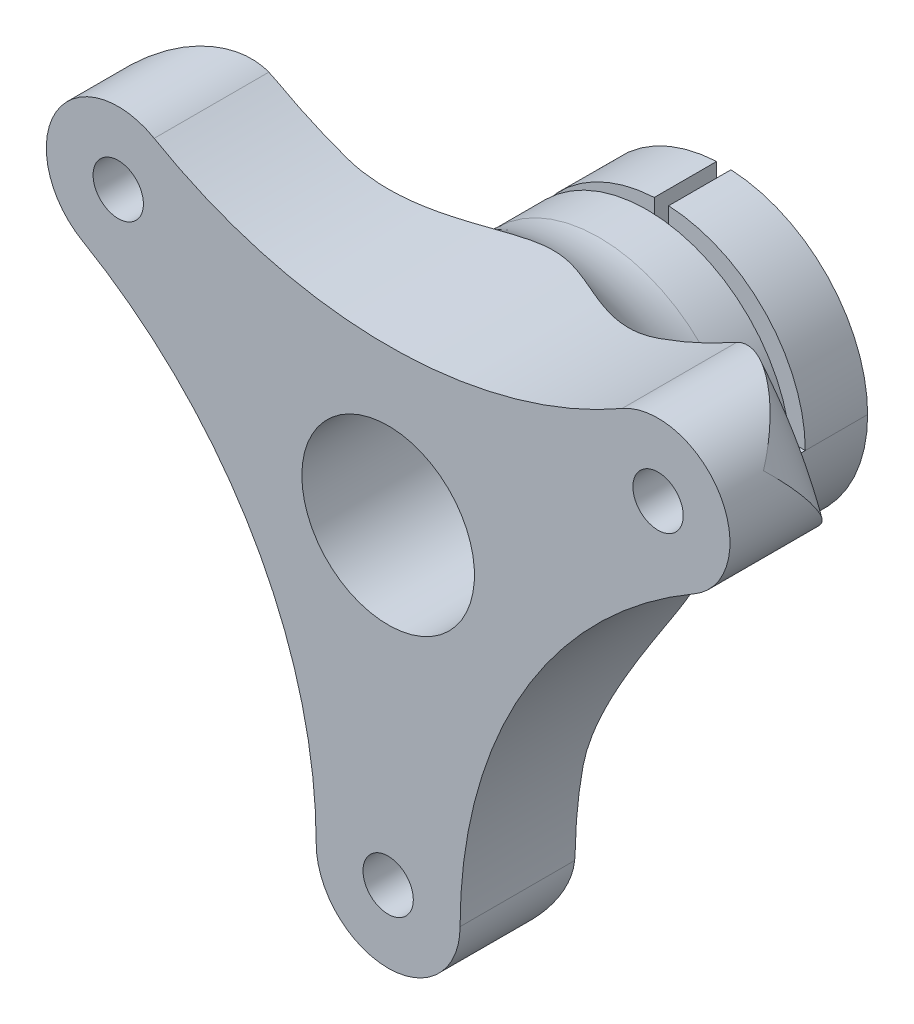
from build123d import *

# Parameters (mm, degrees)
SKETCH2_R          = 11.1125
CUT_EXTRUDE1_DEPTH = 15.875
SKETCH3_W          = 35
SKETCH3_H          = 1.5
CUT_EXTRUDE2_DEPTH = 15.875
SKETCH4_W          = 1.5
SKETCH4_H          = 35
CUT_EXTRUDE3_DEPTH = 8
SKETCH8_OUTSIDE_W  = 105.686
SKETCH8_OUTSIDE_H  = 105.686
CUT_EXTRUDE4_DEPTH = 36
SKETCH9_R          = 9
CUT_EXTRUDE5_DEPTH = 20.1250001
SKETCH5_R          = 2.625
CUT_EXTRUDE7_DEPTH = 36
SKETCH11_R         = 4
CUT_EXTRUDE8_DEPTH = 5


with BuildPart() as part:
    # Sketch1 → Revolve1 (revolve)
    with BuildSketch(Plane(origin=(0, 0, 0), x_dir=(1, 0, 0), z_dir=(0, 1, 0))):
        with BuildLine():
            Line((0, 0), (40, 0))
            Line((40, 0), (40, 4.5))
            ThreePointArc((40, 4.5), (37.803300859, 9.803300859), (32.5, 12))
            Line((32.5, 12), (25, 12))
            ThreePointArc((25, 12), (17.928932188, 14.928932188), (15, 22))
            Line((15, 22), (15, 35))
            Line((15, 35), (0, 35))
            Line((0, 35), (0, 0))
        make_face()
    revolve(axis=Axis((0, 0, 0), (0, 0, -1)))

    # Sketch2 → Cut-Extrude1 (cut)
    with BuildSketch(Plane(origin=(0, 0, -35), x_dir=(-1, 0, 0), z_dir=(0, 0, -1))):
        Circle(SKETCH2_R)
    extrude(amount=-CUT_EXTRUDE1_DEPTH, mode=Mode.SUBTRACT)

    # Sketch3 → Cut-Extrude2 (cut)
    with BuildSketch(Plane(origin=(0, 0, 0), x_dir=(1, 0, 0), z_dir=(0, 1, 0))):
        with Locations((0, 27.75)):
            Rectangle(SKETCH3_W, SKETCH3_H)
    extrude(amount=CUT_EXTRUDE2_DEPTH, mode=Mode.SUBTRACT)

    # Sketch4 → Cut-Extrude3 (cut)
    with BuildSketch(Plane(origin=(0, 0, -35), x_dir=(-1, 0, 0), z_dir=(0, 0, -1))):
        Rectangle(SKETCH4_W, SKETCH4_H)
    extrude(amount=-CUT_EXTRUDE3_DEPTH, mode=Mode.SUBTRACT)

    # Sketch8 outside → Cut-Extrude4 (cut, through all)
    with BuildSketch(Plane.XY):
        Rectangle(SKETCH8_OUTSIDE_W, SKETCH8_OUTSIDE_H)
        with BuildLine():
            ThreePointArc((-24.395825623, 22.745190528), (-34.641016151, 20), (-31.895825623, 9.754809472))
            ThreePointArc((-31.895825623, 9.754809472), (-14.036841774, -8.104174377), (-7.5, -32.5))
            ThreePointArc((-7.5, -32.5), (0, -40), (7.5, -32.5))
            ThreePointArc((7.5, -32.5), (14.036841774, -8.104174377), (31.895825623, 9.754809472))
            ThreePointArc((31.895825623, 9.754809472), (34.641016151, 20), (24.395825623, 22.745190528))
            ThreePointArc((24.395825623, 22.745190528), (0, 16.208348754), (-24.395825623, 22.745190528))
        make_face(mode=Mode.SUBTRACT)
    extrude(amount=-CUT_EXTRUDE4_DEPTH, mode=Mode.SUBTRACT)

    # Sketch9 → Cut-Extrude5 (cut, through all)
    with BuildSketch(Plane(origin=(0, 0, -19.125), x_dir=(-1, 0, 0), z_dir=(0, 0, -1))):
        Circle(SKETCH9_R)
    extrude(amount=-CUT_EXTRUDE5_DEPTH, mode=Mode.SUBTRACT)

    # Sketch5 → Cut-Extrude7 (cut, through all)
    with BuildSketch(Plane.XY):
        with Locations((-28.145825623, 16.25)):
            Circle(SKETCH5_R)
        with Locations((28.145825623, 16.25)):
            Circle(SKETCH5_R)
        with Locations((0, -32.5)):
            Circle(SKETCH5_R)
    extrude(amount=-CUT_EXTRUDE7_DEPTH, mode=Mode.SUBTRACT)

    # Sketch11 → Cut-Extrude8 (cut)
    with BuildSketch(Plane(origin=(0, 0, -12), x_dir=(-1, 0, 0), z_dir=(0, 0, -1))):
        with Locations((-28.145825623, 16.25)):
            Circle(SKETCH11_R)
        with Locations((28.145825623, 16.25)):
            Circle(SKETCH11_R)
        with Locations((0, -32.5)):
            Circle(SKETCH11_R)
    extrude(amount=-CUT_EXTRUDE8_DEPTH, mode=Mode.SUBTRACT)


solid = part.part
